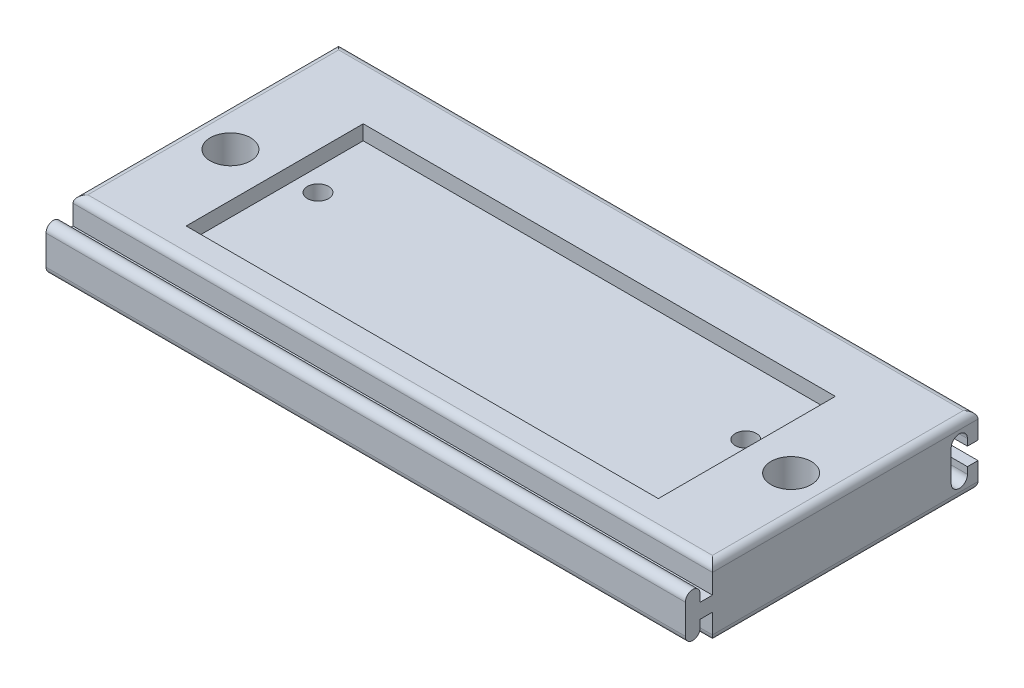
from build123d import *

# Parameters (mm, degrees)
SKETCH1_W           = 130
SKETCH1_H           = 60
SKETCH1_R           = 2.15
SKETCH1_R_2         = 2.65
BOSS_EXTRUDE1_DEPTH = 14
CUT_EXTRUDE1_DEPTH  = 7
SKETCH3_R           = 4.1
CUT_EXTRUDE2_DEPTH  = 7
SKETCH4_W           = 96
SKETCH4_H           = 36
CUT_EXTRUDE3_DEPTH  = 3
CUT_EXTRUDE4_DEPTH  = 130
FILLET1_R           = 1.5


with BuildPart() as part:
    # Sketch1 → Boss-Extrude1 (new body)
    with BuildSketch(Plane(origin=(0, 0, 0), x_dir=(1, 0, 0), z_dir=(0, 1, 0))):
        Rectangle(SKETCH1_W, SKETCH1_H)
        with Locations((-43.5, 4.3)):
            Circle(SKETCH1_R, mode=Mode.SUBTRACT)
        with Locations((43.5, 4.3)):
            Circle(SKETCH1_R, mode=Mode.SUBTRACT)
        with Locations((-57, 0)):
            Circle(SKETCH1_R_2, mode=Mode.SUBTRACT)
        with Locations((57, 0)):
            Circle(SKETCH1_R_2, mode=Mode.SUBTRACT)
    extrude(amount=BOSS_EXTRUDE1_DEPTH)

    # Sketch2 → Cut-Extrude1 (cut)
    with BuildSketch(Plane.XZ):
        Polygon((-39.577622793, -5.676574387), (-40.346663007, -1.591408889), (-44.269040214, -0.214834502), (-47.422377207, -2.923425613), (-46.653336993, -7.008591111), (-42.730959786, -8.385165498), align=None)
        Polygon((42.815034421, -8.400100262), (46.708308195, -6.943247723), (47.393273774, -2.843147461), (44.184965579, -0.199899738), (40.291691805, -1.656752277), (39.606726226, -5.756852539), align=None)
    extrude(amount=-CUT_EXTRUDE1_DEPTH, mode=Mode.SUBTRACT)

    # Sketch3 → Cut-Extrude2 (cut)
    with BuildSketch(Plane(origin=(0, 14, 0), x_dir=(1, 0, 0), z_dir=(0, 1, 0))):
        with Locations((-57, 0)):
            Circle(SKETCH3_R)
        with Locations((57, 0)):
            Circle(SKETCH3_R)
    extrude(amount=-CUT_EXTRUDE2_DEPTH, mode=Mode.SUBTRACT)

    # Sketch4 → Cut-Extrude3 (cut)
    with BuildSketch(Plane(origin=(0, 14, 0), x_dir=(1, 0, 0), z_dir=(0, 1, 0))):
        Rectangle(SKETCH4_W, SKETCH4_H)
    extrude(amount=-CUT_EXTRUDE3_DEPTH, mode=Mode.SUBTRACT)

    # Sketch5 → Cut-Extrude4 (cut)
    with BuildSketch(Plane(origin=(65, 0, 0), x_dir=(0, 0, -1), z_dir=(1, 0, 0))):
        with BuildLine():
            Line((-24, 14), (-24, 8.5))
            Line((-24, 8.5), (-26.5, 8.5))
            Line((-26.5, 8.5), (-26.5, 10))
            ThreePointArc((-26.5, 10), (-28, 11.5), (-29.5, 10))
            Line((-29.5, 10), (-29.5, 4))
            ThreePointArc((-29.5, 4), (-28, 2.5), (-26.5, 4))
            Line((-26.5, 4), (-26.5, 5.5))
            Line((-26.5, 5.5), (-24, 5.5))
            Line((-24, 5.5), (-24, 0))
            Line((-24, 0), (-30, 0))
            Line((-30, 0), (-30, 14))
            Line((-30, 14), (-24, 14))
        make_face()
        with BuildLine():
            Line((27.85, 8.8), (30, 8.8))
            Line((30, 8.8), (30, 5.2))
            Line((30, 5.2), (27.85, 5.2))
            Line((27.85, 5.2), (27.85, 3.85))
            ThreePointArc((27.85, 3.85), (26.2, 2.2), (24.55, 3.85))
            Line((24.55, 3.85), (24.55, 10.15))
            ThreePointArc((24.55, 10.15), (26.2, 11.8), (27.85, 10.15))
            Line((27.85, 10.15), (27.85, 8.8))
        make_face()
    extrude(amount=-CUT_EXTRUDE4_DEPTH, mode=Mode.SUBTRACT)

    # Fillet1
    fillet1_edges = [part.edges().sort_by_distance(p)[0] for p in [
        (65, 0, -3),
        (65, 14, -3),
        (0, 14, 24),
        (0, 0, 24),
        (-65, 14, -3),
        (-65, 0, -3),
        (0, 0, -30),
        (0, 14, -30),
    ]]
    fillet(fillet1_edges, radius=FILLET1_R)


solid = part.part
